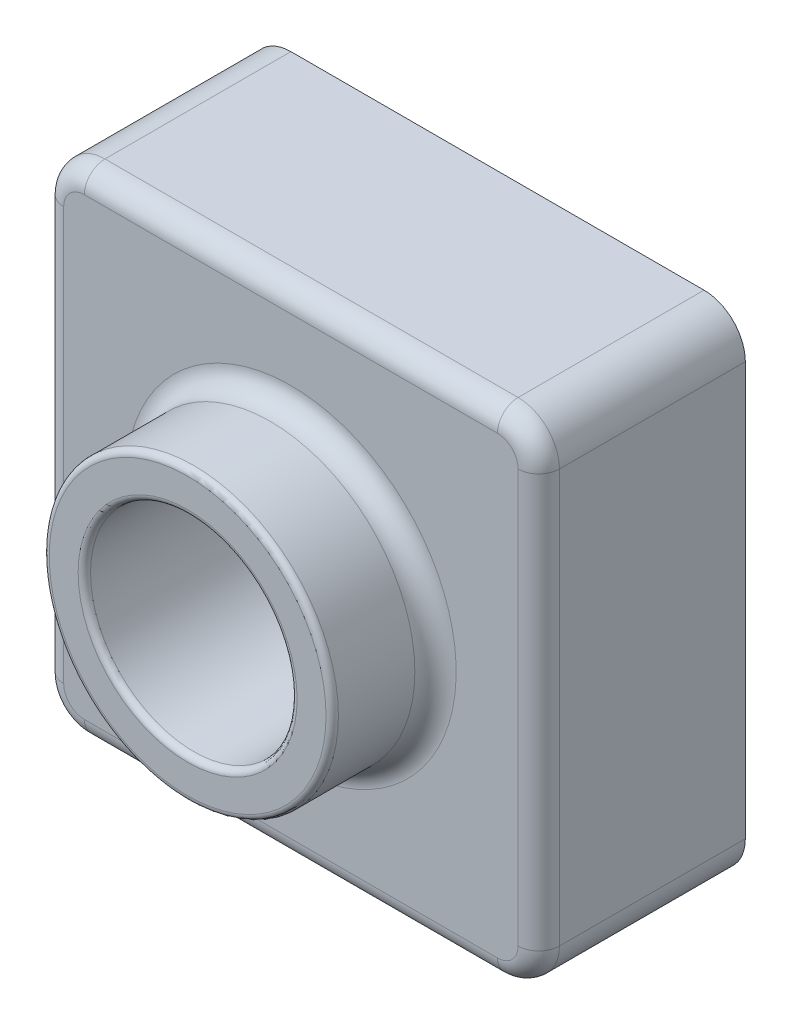
from build123d import *

# Parameters (mm, degrees)
SKETCH2_W           = 120
SKETCH2_H           = 120
BOSS_EXTRUDE2_DEPTH = 50
SKETCH6_R           = 35
BOSS_EXTRUDE3_DEPTH = 25
SKETCH11_R          = 25
CUT_EXTRUDE1_DEPTH  = 76
FILLET3_R           = 10
FILLET4_R           = 1.5
FILLET5_R           = 5
SHELL2_T            = -2


with BuildPart() as part:
    # Sketch2 → Boss-Extrude2 (new body)
    with BuildSketch(Plane.XY):
        with Locations((60, 60)):
            Rectangle(SKETCH2_W, SKETCH2_H)
    extrude(amount=BOSS_EXTRUDE2_DEPTH)

    # Sketch6 → Boss-Extrude3 (add)
    with BuildSketch(Plane.XY.offset(50)):
        with Locations((60, 60)):
            Circle(SKETCH6_R)
    extrude(amount=BOSS_EXTRUDE3_DEPTH)

    # Sketch11 → Cut-Extrude1 (cut, through all)
    with BuildSketch(Plane.XY.offset(75)):
        with Locations((60, 60)):
            Circle(SKETCH11_R)
    extrude(amount=-CUT_EXTRUDE1_DEPTH, mode=Mode.SUBTRACT)

    # Fillet3
    fillet3_edges = [part.edges().sort_by_distance(p)[0] for p in [
        (0, 120, 25),
        (120, 120, 25),
        (120, 0, 25),
        (0, 0, 25),
    ]]
    fillet(fillet3_edges, radius=FILLET3_R)

    # Fillet4
    fillet4_edges = [part.edges().sort_by_distance(p)[0] for p in [
        (25, 60, 75),
        (35, 60, 75),
    ]]
    fillet(fillet4_edges, radius=FILLET4_R)

    # Fillet5
    fillet5_edges = [part.edges().sort_by_distance(p)[0] for p in [
        (25, 60, 50),
        (60, 0, 50),
        (0, 60, 50),
        (120, 60, 50),
        (60, 120, 50),
        (117.071067812, 117.071067812, 50),
        (117.071067812, 2.928932188, 50),
        (2.928932188, 117.071067812, 50),
        (2.928932188, 2.928932188, 50),
    ]]
    fillet(fillet5_edges, radius=FILLET5_R)

    # Shell2
    shell2_openings = [part.faces().sort_by_distance(p)[0] for p in [
        (85, 60, 0),
    ]]
    offset(amount=SHELL2_T, openings=shell2_openings, kind=Kind.INTERSECTION)


solid = part.part
